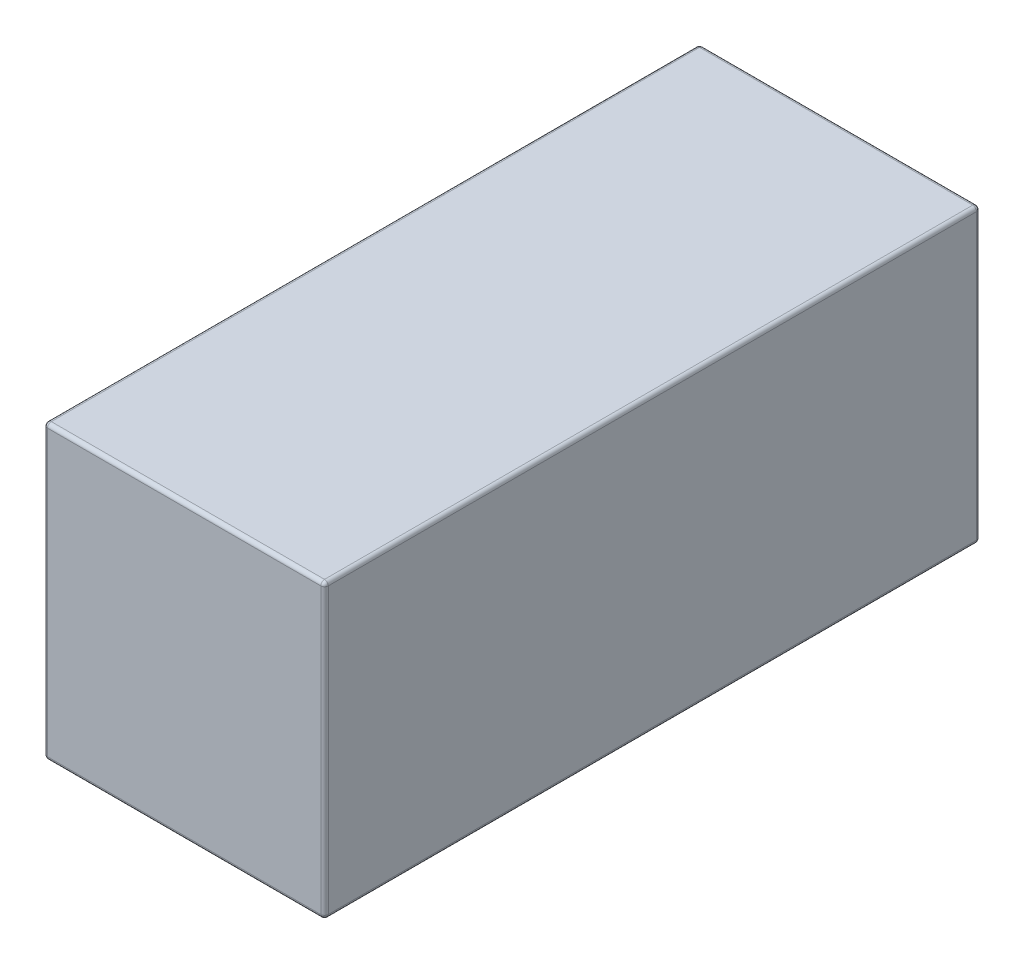
from build123d import *

# Parameters (mm, degrees)
SKETCH1_W           = 37.25
SKETCH1_H           = 38.75
BOSS_EXTRUDE1_DEPTH = 43.5
FILLET1_R           = 0.5


with BuildPart() as part:
    # Sketch1 → Boss-Extrude1 (new body, symmetric)
    with BuildSketch(Plane.XY):
        Rectangle(SKETCH1_W, SKETCH1_H)
    extrude(amount=BOSS_EXTRUDE1_DEPTH, both=True)

    # Fillet1
    fillet1_edges = [part.edges().sort_by_distance(p)[0] for p in [
        (-18.625, 0, 43.5),
        (0, -19.375, 43.5),
        (18.625, 0, 43.5),
        (0, -19.375, -43.5),
        (-18.625, 0, -43.5),
        (0, 19.375, -43.5),
        (18.625, 0, -43.5),
        (0, 19.375, 43.5),
        (18.625, -19.375, 0),
        (-18.625, -19.375, 0),
        (-18.625, 19.375, 0),
        (18.625, 19.375, 0),
    ]]
    fillet(fillet1_edges, radius=FILLET1_R)


solid = part.part
